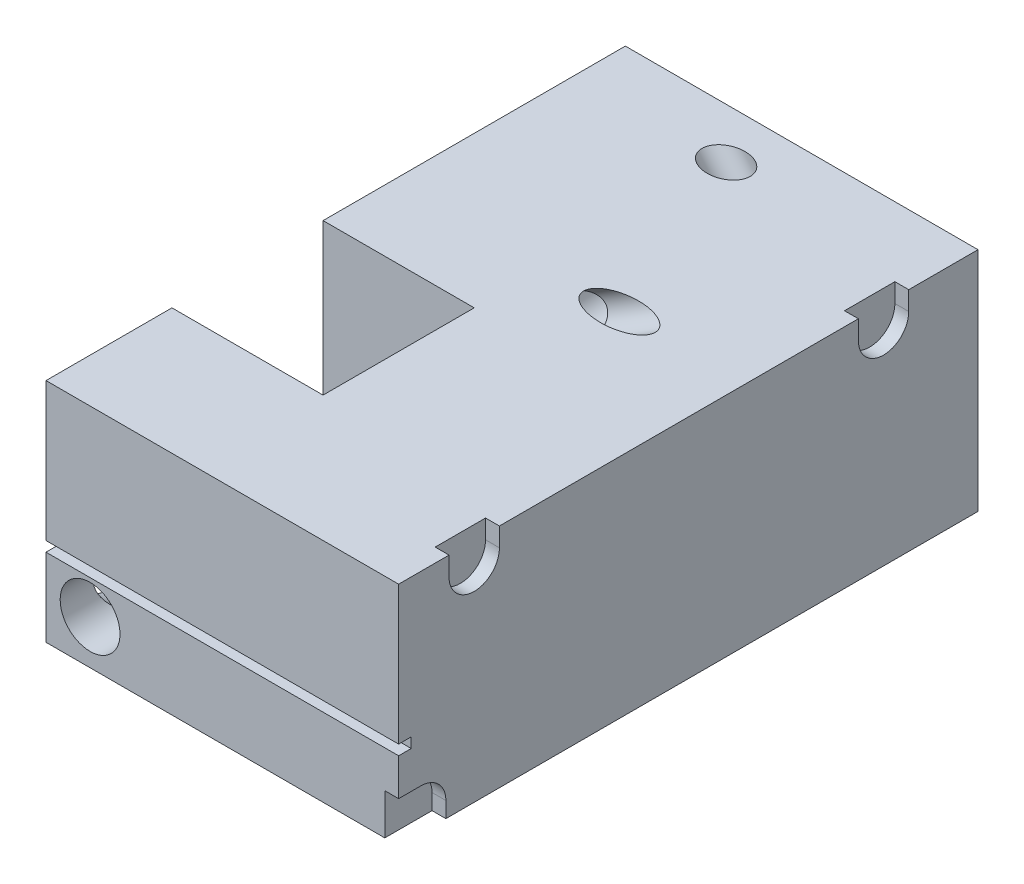
from build123d import *

# Parameters (mm, degrees)
SKETCH_1_W                      = 56
SKETCH_1_H                      = 36
EXTRUDE_1_DEPTH                 = 92
SKETCH_2_R                      = 14
CUT_EXTRUDE_1_DEPTH             = 82
SKETCH_5_R                      = 12
SKETCH_5_R_2                    = 3.5
CUT_EXTRUDE_2_DEPTH             = 40
CUT_EXTRUDE_4_DEPTH             = 37
SKETCH_6_R                      = 4.75
CUT_EXTRUDE_3_DEPTH             = 60
CUT_EXTRUDE_8_REACH             = 28.427
SKETCH_15_R                     = 3
CUT_EXTRUDE_8_DIRECTION_2_REACH = 42.138
CUT_EXTRUDE_9_REACH             = 23.396
SKETCH_16_R                     = 3
CUT_EXTRUDE_9_DIRECTION_2_REACH = 43.698
SKETCH_20_R                     = 4.75
CUT_EXTRUDE_13_DEPTH            = 38
CUT_EXTRUDE_14_REACH            = 38
SKETCH_21_R                     = 3
CUT_EXTRUDE_15_DEPTH            = 2.2
SKETCH_23_W                     = 2
SKETCH_23_H                     = 1.6
CUT_EXTRUDE_16_DEPTH            = 57


with BuildPart() as part:
    # Эскиз1 → Бобышка-Вытянуть1 (new body)
    with BuildSketch(Plane.XY):
        with Locations((-28, 18)):
            Rectangle(SKETCH_1_W, SKETCH_1_H)
    extrude(amount=EXTRUDE_1_DEPTH)

    # Эскиз2 → Вырез-Вытянуть1 (cut)
    with BuildSketch(Plane(origin=(0, 0, 0), x_dir=(-1, 0, 0), z_dir=(0, 0, -1))):
        with Locations((16, 16)):
            Circle(SKETCH_2_R)
    extrude(amount=-CUT_EXTRUDE_1_DEPTH, mode=Mode.SUBTRACT)

    # Эскиз5 → Вырез-Вытянуть2 (cut)
    with BuildSketch(Plane(origin=(0, 0, 0), x_dir=(-1, 0, 0), z_dir=(0, 0, -1))):
        with Locations((42.5, 22)):
            Circle(SKETCH_5_R)
        with Locations((28, 31)):
            Circle(SKETCH_5_R_2)
    extrude(amount=-CUT_EXTRUDE_2_DEPTH, mode=Mode.SUBTRACT)

    # Эскиз7 → Вырез-Вытянуть4 (cut, through all)
    with BuildSketch(Plane.XZ):
        Polygon((-248.428068016, 48), (-56, 48), (-32, 48), (-32, 72), (-56, 72), (-248.428068016, 72), (-633.284204048, 72), (-633.284204048, 48), align=None)
    extrude(amount=-CUT_EXTRUDE_4_DEPTH, mode=Mode.SUBTRACT)

    # Эскиз6 → Вырез-Вытянуть3 (cut)
    with BuildSketch(Plane(origin=(0, 0, 92), x_dir=(-1, 0, 0), z_dir=(0, 0, -1))):
        with Locations((49, 7)):
            Circle(SKETCH_6_R)
    extrude(amount=CUT_EXTRUDE_3_DEPTH, mode=Mode.SUBTRACT)

    # Эскиз15 → Вырез-Вытянуть8 (cut, up to next)
    with BuildSketch(Plane(origin=(-6.322746781, -3.924463519, 0), x_dir=(0, 0, 1), z_dir=(-0.849640166, -0.527362862, 0)), mode=Mode.PRIVATE) as cut_extrude_8_sk1:
        with Locations((37, 41.105005282)):
            Circle(SKETCH_15_R)
    cut_extrude_8_tool1 = extrude(cut_extrude_8_sk1.sketch, amount=-CUT_EXTRUDE_8_REACH, mode=Mode.PRIVATE) & part.part
    add(cut_extrude_8_tool1.solids().sort_by_distance((-28, 31, 37))[0], mode=Mode.SUBTRACT)

    # Эскиз15 → Вырез-Вытянуть8 direction 2 (cut, up to next)
    with BuildSketch(Plane(origin=(-6.322746781, -3.924463519, 0), x_dir=(0, 0, 1), z_dir=(-0.849640166, -0.527362862, 0)), mode=Mode.PRIVATE) as cut_extrude_8_direction_2_sk1:
        with Locations((37, 41.105005282)):
            Circle(SKETCH_15_R)
    cut_extrude_8_direction_2_tool1 = extrude(cut_extrude_8_direction_2_sk1.sketch, amount=CUT_EXTRUDE_8_DIRECTION_2_REACH, mode=Mode.PRIVATE) & part.part
    add(cut_extrude_8_direction_2_tool1.solids().sort_by_distance((-28, 31, 37))[0], mode=Mode.SUBTRACT)

    # Эскиз16 → Вырез-Вытянуть9 (cut, up to next)
    with BuildSketch(Plane(origin=(-26.048780488, 32.56097561, 0), x_dir=(0.780868809, 0.624695048, 0), z_dir=(0.624695048, -0.780868809, 0)), mode=Mode.PRIVATE) as cut_extrude_9_sk1:
        with Locations((-2.49878019, 8)):
            Circle(SKETCH_16_R)
    cut_extrude_9_tool1 = extrude(cut_extrude_9_sk1.sketch, amount=-CUT_EXTRUDE_9_REACH, mode=Mode.PRIVATE) & part.part
    add(cut_extrude_9_tool1.solids().sort_by_distance((-28, 31, 8))[0], mode=Mode.SUBTRACT)

    # Эскиз16 → Вырез-Вытянуть9 direction 2 (cut, up to next)
    with BuildSketch(Plane(origin=(-26.048780488, 32.56097561, 0), x_dir=(0.780868809, 0.624695048, 0), z_dir=(0.624695048, -0.780868809, 0)), mode=Mode.PRIVATE) as cut_extrude_9_direction_2_sk1:
        with Locations((-2.49878019, 8)):
            Circle(SKETCH_16_R)
    cut_extrude_9_direction_2_tool1 = extrude(cut_extrude_9_direction_2_sk1.sketch, amount=CUT_EXTRUDE_9_DIRECTION_2_REACH, mode=Mode.PRIVATE) & part.part
    add(cut_extrude_9_direction_2_tool1.solids().sort_by_distance((-28, 31, 8))[0], mode=Mode.SUBTRACT)

    # Эскиз20 → Вырез-Вытянуть13 (cut)
    with BuildSketch(Plane.ZY.offset(56)):
        with Locations((82, 7)):
            Circle(SKETCH_20_R)
    extrude(amount=-CUT_EXTRUDE_13_DEPTH, mode=Mode.SUBTRACT)

    # Эскиз21 → Вырез-Вытянуть14 (cut, up to next)
    with BuildSketch(Plane.XZ, mode=Mode.PRIVATE) as cut_extrude_14_sk1:
        with Locations((-47, 16)):
            Circle(SKETCH_21_R)
    cut_extrude_14_tool1 = extrude(cut_extrude_14_sk1.sketch, amount=-CUT_EXTRUDE_14_REACH, mode=Mode.PRIVATE) & part.part
    add(cut_extrude_14_tool1.solids().sort_by_distance((-47, 0, 16))[0], mode=Mode.SUBTRACT)

    # Эскиз22 → Вырез-Вытянуть15 (cut)
    with BuildSketch(Plane(origin=(0, 0, 0), x_dir=(0, 0, -1), z_dir=(1, 0, 0))):
        with BuildLine():
            Line((-92, 0), (-84.5, 0))
            Line((-84.5, 0), (-84.5, 2.5))
            ThreePointArc((-84.5, 2.5), (-85.671572875, 5.328427125), (-88.5, 6.5))
            Line((-88.5, 6.5), (-92, 6.5))
            Line((-92, 6.5), (-92, 0))
        make_face()
        with BuildLine():
            Line((-76, 36), (-84, 36))
            Line((-84, 36), (-84, 33))
            ThreePointArc((-84, 33), (-80, 29), (-76, 33))
            Line((-76, 33), (-76, 36))
        make_face()
        with BuildLine():
            Line((-11, 36), (-19, 36))
            Line((-19, 36), (-19, 33))
            ThreePointArc((-19, 33), (-15, 29), (-11, 33))
            Line((-11, 33), (-11, 36))
        make_face()
    extrude(amount=-CUT_EXTRUDE_15_DEPTH, mode=Mode.SUBTRACT)

    # Эскиз23 → Вырез-Вытянуть16 (cut, through all)
    with BuildSketch(Plane(origin=(0, 0, 0), x_dir=(0, 0, -1), z_dir=(1, 0, 0))):
        with Locations((-91, 13.2)):
            Rectangle(SKETCH_23_W, SKETCH_23_H)
    extrude(amount=-CUT_EXTRUDE_16_DEPTH, mode=Mode.SUBTRACT)


solid = part.part
